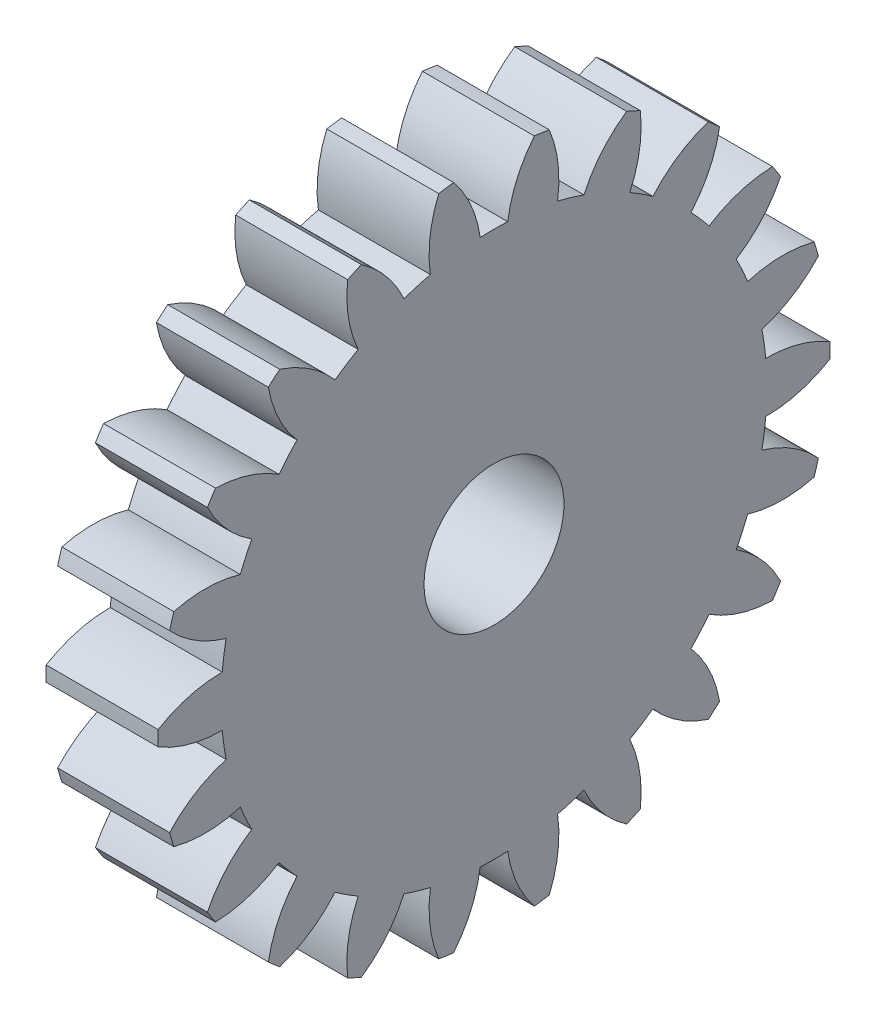
from build123d import *

# Parameters (mm, degrees)
BASPROSKE_W     = 4
BASPROSKE_H     = 12
TOOTHCUT_DEPTH  = 18.435595774
TEETHCUTS_COUNT = 22
TEETHCUTS_ANGLE = 343.636363636
BORSKE_R        = 2.5
BORE_DEPTH      = 50.0000508


with BuildPart() as part:
    # BasProSke → Base-Revolve (revolve)
    with BuildSketch(Plane(origin=(0, 0, 0), x_dir=(1, 0, 0), z_dir=(0, 1, 0)), mode=Mode.PRIVATE) as base_revolve_sk:
        with Locations((2, 6)):
            Rectangle(BASPROSKE_W, BASPROSKE_H)
    revolve(base_revolve_sk.sketch.rotate(Axis((-10, 0, 0), (1, 0, 0)), 180), axis=Axis((-10, 0, 0), (1, 0, 0)))

    # TooCutSke → ToothCut (cut, through all)
    with BuildSketch(Plane(origin=(0, 0, 0), x_dir=(0, 0, -1), z_dir=(1, 0, 0))):
        with BuildLine():
            ThreePointArc((0.491001901, 9.736627657), (0, 9.749), (-0.491001901, 9.736627657))
            ThreePointArc((-0.491001901, 9.736627657), (-0.822824844, 10.904005344), (-1.46093845, 11.936327074))
            ThreePointArc((-1.46093845, 11.936327074), (0, 12.0254), (1.46093845, 11.936327074))
            ThreePointArc((1.46093845, 11.936327074), (0.822824844, 10.904005344), (0.491001901, 9.736627657))
        make_face()
    toothcut = extrude(amount=TOOTHCUT_DEPTH, mode=Mode.SUBTRACT)

    # TeethCuts: ToothCut ×22 about axis
    teethcuts_axis = Axis((-10, 0, 0), (1, 0, 0))
    for i in range(1, TEETHCUTS_COUNT):
        add(toothcut.rotate(teethcuts_axis, i * TEETHCUTS_ANGLE / (TEETHCUTS_COUNT - 1)), mode=Mode.SUBTRACT)

    # BorSke → Bore (cut, symmetric)
    with BuildSketch(Plane(origin=(0, 0, 0), x_dir=(0, 0, -1), z_dir=(1, 0, 0))):
        with Locations(Location((0, 0, 0), (0, 0, 180))):
            Circle(BORSKE_R)
    extrude(amount=BORE_DEPTH, both=True, mode=Mode.SUBTRACT)


solid = part.part
